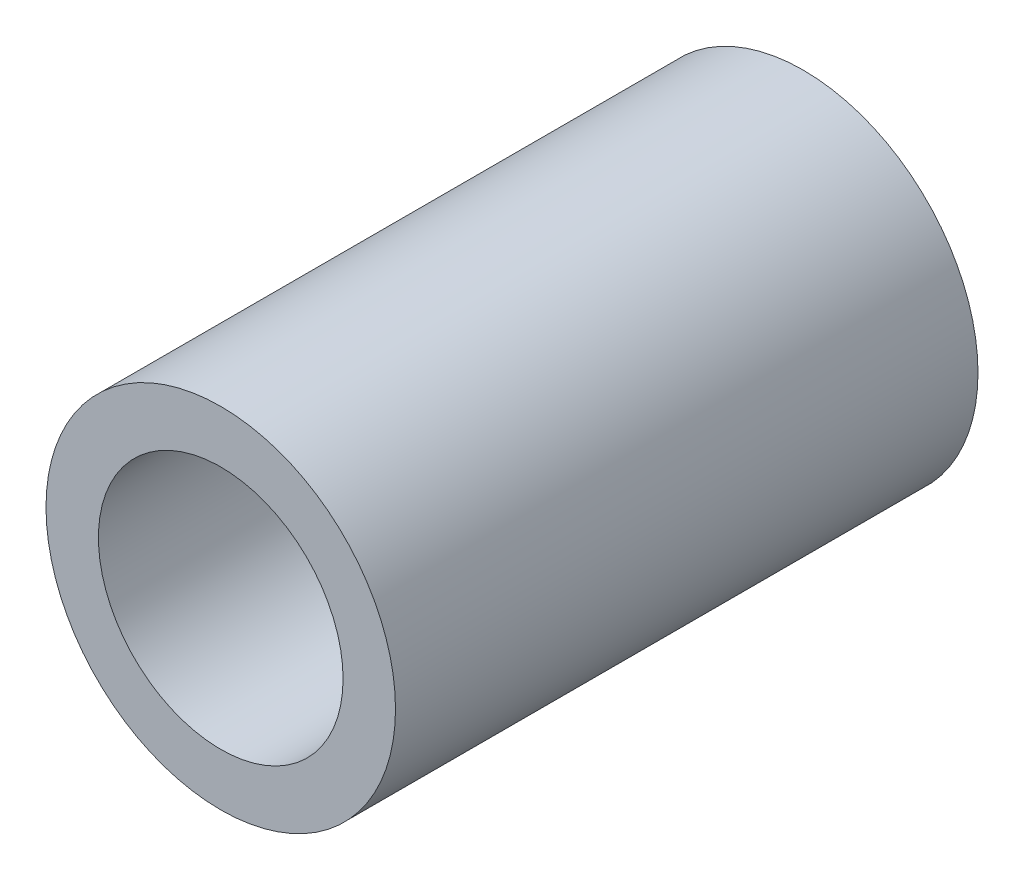
from build123d import *

# Parameters (mm, degrees)
SKETCH1_R      = 3
SKETCH1_R_2    = 2.1
EXTRUDE1_DEPTH = 5


with BuildPart() as part:
    # Sketch1 → Extrude1 (new body, symmetric)
    with BuildSketch(Plane.XY):
        Circle(SKETCH1_R)
        Circle(SKETCH1_R_2, mode=Mode.SUBTRACT)
    extrude(amount=EXTRUDE1_DEPTH, both=True)


solid = part.part
